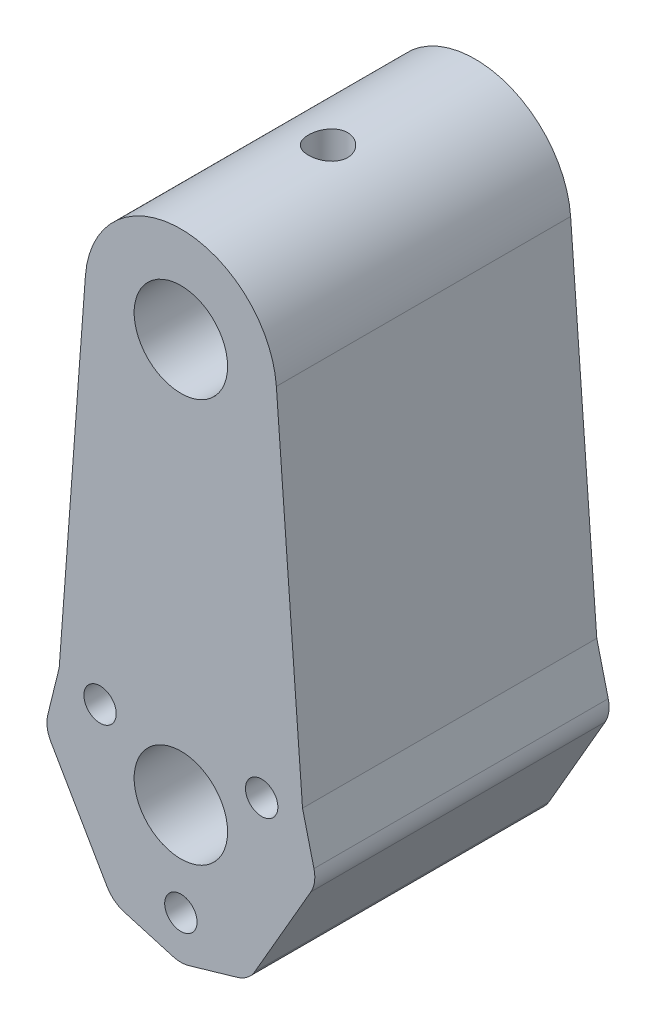
from build123d import *

# Parameters (mm, degrees)
SKETCH1_R           = 4.7625
SKETCH1_R_2         = 1.65
BOSS_EXTRUDE1_DEPTH = 15
SKETCH2_R           = 4.7625
BOSS_EXTRUDE2_DEPTH = 15
CUT_EXTRUDE1_REACH  = 66.755
SKETCH3_R           = 2


with BuildPart() as part:
    # Sketch1 → Boss-Extrude1 (new body, symmetric)
    with BuildSketch(Plane.XY):
        with BuildLine():
            Line((-13.253372163, -1.044486042), (-7.531237528, -10.955513958))
            ThreePointArc((-7.531237528, -10.955513958), (-6.784217233, -11.816359568), (-5.770008435, -12.336431676))
            Line((-5.770008435, -12.336431676), (-0.836847118, -13.76941319))
            ThreePointArc((-0.836847118, -13.76941319), (0, -13.888495471), (0.836847118, -13.76941319))
            Line((0.836847118, -13.76941319), (5.770008435, -12.336431676))
            ThreePointArc((5.770008435, -12.336431676), (6.784217233, -11.816359568), (7.531237528, -10.955513958))
            Line((7.531237528, -10.955513958), (13.253372163, -1.044486042))
            ThreePointArc((13.253372163, -1.044486042), (13.625376182, 0.032875315), (13.568667441, 1.171241953))
            Line((13.568667441, 1.171241953), (12.343085176, 6.159975731))
            ThreePointArc((12.343085176, 6.159975731), (12.027789898, 6.944247736), (11.506238058, 7.609437458))
            Line((11.506238058, 7.609437458), (7.798659006, 11.165189723))
            ThreePointArc((7.798659006, 11.165189723), (6.841158949, 11.783484253), (5.722134635, 12))
            Line((5.722134635, 12), (-5.722134635, 12))
            ThreePointArc((-5.722134635, 12), (-6.841158949, 11.783484253), (-7.798659006, 11.165189723))
            Line((-7.798659006, 11.165189723), (-11.506238058, 7.609437458))
            ThreePointArc((-11.506238058, 7.609437458), (-12.027789898, 6.944247736), (-12.343085176, 6.159975731))
            Line((-12.343085176, 6.159975731), (-13.568667441, 1.171241953))
            ThreePointArc((-13.568667441, 1.171241953), (-13.625376182, 0.032875315), (-13.253372163, -1.044486042))
        make_face()
        Circle(SKETCH1_R, mode=Mode.SUBTRACT)
        with Locations((-8.238066653, 4.75625)):
            Circle(SKETCH1_R_2, mode=Mode.SUBTRACT)
        with Locations((8.238066653, 4.75625)):
            Circle(SKETCH1_R_2, mode=Mode.SUBTRACT)
        with Locations((0, -9.5125)):
            Circle(SKETCH1_R_2, mode=Mode.SUBTRACT)
    extrude(amount=BOSS_EXTRUDE1_DEPTH, both=True)

    # Sketch2 → Boss-Extrude2 (add, symmetric)
    with BuildSketch(Plane.XY):
        with BuildLine():
            Line((-12.421472807, 5.666457921), (-9.735682804, 41.826981922))
            ThreePointArc((-9.735682804, 41.826981922), (0, 50.866372944), (9.735682804, 41.826981922))
            Line((9.735682804, 41.826981922), (12.421472807, 5.666457921))
            Line((12.421472807, 5.666457921), (0, 12))
            Line((0, 12), (-12.421472807, 5.666457921))
        make_face()
        with Locations((0, 41.103872944)):
            Circle(SKETCH2_R, mode=Mode.SUBTRACT)
    extrude(amount=BOSS_EXTRUDE2_DEPTH, both=True)

    # Sketch3 → Cut-Extrude1 (cut, up to next)
    with BuildSketch(Plane(origin=(0, 50.866372944, 0), x_dir=(1, 0, 0), z_dir=(0, 1, 0)), mode=Mode.PRIVATE) as cut_extrude1_sk1:
        Circle(SKETCH3_R)
    cut_extrude1_tool1 = extrude(cut_extrude1_sk1.sketch, amount=-CUT_EXTRUDE1_REACH, mode=Mode.PRIVATE) & part.part
    add(cut_extrude1_tool1.solids().sort_by_distance((0, 50.866373, 0))[0], mode=Mode.SUBTRACT)


solid = part.part
